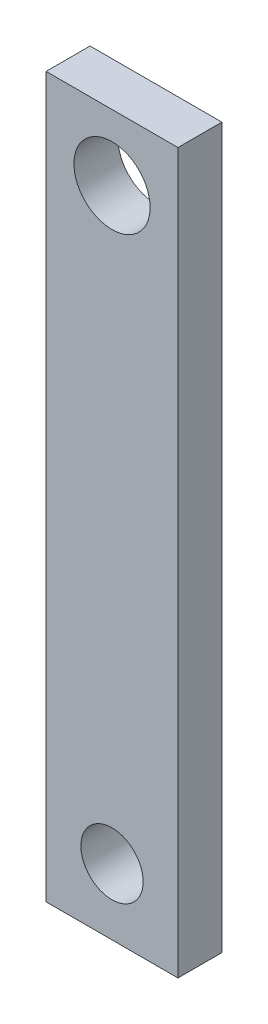
from build123d import *

# Parameters (mm, degrees)
SKETCH1_W                 = 19.05
SKETCH1_H                 = 103.886
BOSS_EXTRUDE1_DEPTH       = 6.35
M8_CLEARANCE_HOLE1_D      = 9
M8_CLEARANCE_HOLE1_DEPTH  = 21.082
M8_CLEARANCE_HOLE1_TIP    = 2.703872786
M10_CLEARANCE_HOLE1_D     = 11
M10_CLEARANCE_HOLE1_DEPTH = 21.082
M10_CLEARANCE_HOLE1_TIP   = 3.304733405


with BuildPart() as part:
    # Sketch1 → Boss-Extrude1 (new body)
    with BuildSketch(Plane.XY):
        with Locations((0, -84.724)):
            Rectangle(SKETCH1_W, SKETCH1_H)
    extrude(amount=BOSS_EXTRUDE1_DEPTH)

    # M8 Clearance Hole1
    with Locations(Plane.XY.offset(6.35)):
        with Locations((0, -127.142)):
            Hole(M8_CLEARANCE_HOLE1_D / 2, depth=M8_CLEARANCE_HOLE1_DEPTH)
            with Locations((0, 0, -(M8_CLEARANCE_HOLE1_DEPTH + M8_CLEARANCE_HOLE1_TIP / 2))):  # 118° drill point
                Cone(0, M8_CLEARANCE_HOLE1_D / 2, M8_CLEARANCE_HOLE1_TIP, mode=Mode.SUBTRACT)

    # M10 Clearance Hole1
    with Locations(Plane.XY.offset(6.35)):
        with Locations((0, -42.306)):
            Hole(M10_CLEARANCE_HOLE1_D / 2, depth=M10_CLEARANCE_HOLE1_DEPTH)
            with Locations((0, 0, -(M10_CLEARANCE_HOLE1_DEPTH + M10_CLEARANCE_HOLE1_TIP / 2))):  # 118° drill point
                Cone(0, M10_CLEARANCE_HOLE1_D / 2, M10_CLEARANCE_HOLE1_TIP, mode=Mode.SUBTRACT)


solid = part.part
